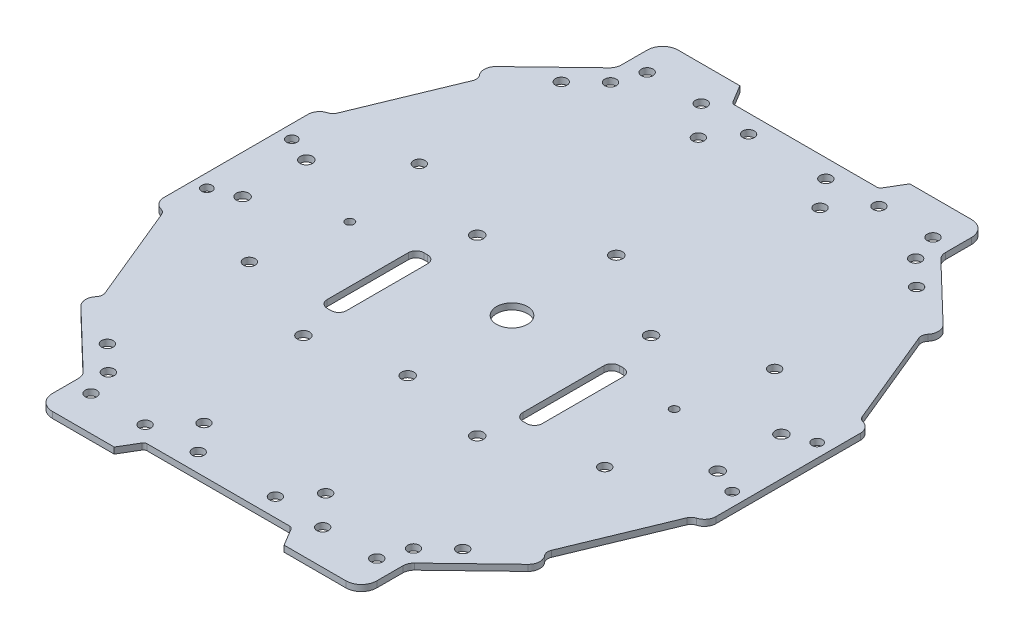
from build123d import *

# Parameters (mm, degrees)
SKETCH1_R        = 4
SKETCH1_R_2      = 1.5
SKETCH1_R_3      = 1.600010398
SKETCH1_R_4      = 1.35
SKETCH1_R_5      = 1.6
EXTRUSION1_DEPTH = 1.6
FILLET1_R        = 1
FILLET2_R        = 4
FILLET3_R        = 3
FILLET4_R        = 3
FILLET5_R        = 2
FILLET6_R        = 2
FILLET7_R        = 3
FILLET8_R        = 3
FILLET9_R        = 2
FILLET10_R       = 2
FILLET11_R       = 3


with BuildPart() as part:
    # Sketch1 → Extrusion1 (new body)
    with BuildSketch(Plane(origin=(0, 0, 0), x_dir=(-1, 0, 0), z_dir=(0, 1, 0))):
        Polygon((97.775158519, 107.059873524), (100.775158519, 102.059873961), (120.775158519, 102.059873961), (120.775158519, 114.059873961), (138.794986286, 131.388630617), (136.022385221, 134.27180306), (147.275158457, 161.559884829), (150.275158519, 161.559884829), (150.275158519, 183.059873956), (150.275158519, 204.559863083), (147.275158457, 204.559863083), (136.022385221, 231.847944851), (138.794986286, 234.731117294), (120.775158519, 252.05987395), (120.775158519, 264.05987395), (100.775158519, 264.05987395), (97.775158519, 259.059874387), (78.775158519, 259.059874387), (59.775158519, 259.059874387), (56.775158519, 264.05987395), (36.775158519, 264.05987395), (36.775158519, 252.05987395), (18.755330752, 234.731117294), (21.527931817, 231.847944851), (10.275158581, 204.559863083), (7.275158519, 204.559863083), (7.275158519, 183.059873956), (7.275158519, 161.559884829), (10.275158581, 161.559884829), (21.527931817, 134.27180306), (18.755330752, 131.388630617), (36.775158519, 114.059873961), (36.775158519, 102.059873961), (56.775158519, 102.059873961), (59.775158519, 107.059873524), (78.775158519, 107.059873524), align=None)
        with Locations((78.775158519, 183.059873956)):
            Circle(SKETCH1_R, mode=Mode.SUBTRACT)
        with Locations((41.775158457, 111.059884829)):
            Circle(SKETCH1_R_2, mode=Mode.SUBTRACT)
        with Locations((68.775158457, 111.809884829)):
            Circle(SKETCH1_R_2, mode=Mode.SUBTRACT)
        with Locations((101.275158519, 169.559873956)):
            Circle(SKETCH1_R_3, mode=Mode.SUBTRACT)
        with Locations((56.275158519, 169.559873956)):
            Circle(SKETCH1_R_3, mode=Mode.SUBTRACT)
        with Locations((10.775158457, 172.059872631)):
            Circle(SKETCH1_R_4, mode=Mode.SUBTRACT)
        with Locations((68.775158457, 254.309863083)):
            Circle(SKETCH1_R_2, mode=Mode.SUBTRACT)
        with Locations((55.775158457, 255.05987528)):
            Circle(SKETCH1_R_2, mode=Mode.SUBTRACT)
        with Locations((32.775158457, 205.059871914)):
            Circle(SKETCH1_R_2, mode=Mode.SUBTRACT)
        with Locations((17.275158457, 191.30987528)):
            Circle(SKETCH1_R_5, mode=Mode.SUBTRACT)
        with Locations((94.525158581, 119.059884829)):
            Circle(SKETCH1_R_2, mode=Mode.SUBTRACT)
        with Locations((101.775158581, 111.059872631)):
            Circle(SKETCH1_R_2, mode=Mode.SUBTRACT)
        with Locations((124.775158581, 161.059875997)):
            Circle(SKETCH1_R_2, mode=Mode.SUBTRACT)
        with Locations((146.775158581, 172.059872631)):
            Circle(SKETCH1_R_4, mode=Mode.SUBTRACT)
        with Locations((118.275158581, 248.059863083)):
            Circle(SKETCH1_R_2, mode=Mode.SUBTRACT)
        with Locations((101.775158581, 255.05987528)):
            Circle(SKETCH1_R_2, mode=Mode.SUBTRACT)
        with Locations((94.525158581, 247.059863083)):
            Circle(SKETCH1_R_2, mode=Mode.SUBTRACT)
        with Locations((124.775158581, 205.059871914)):
            Circle(SKETCH1_R_2, mode=Mode.SUBTRACT)
        with Locations((146.775158581, 194.05987528)):
            Circle(SKETCH1_R_4, mode=Mode.SUBTRACT)
        with Locations((140.275158581, 191.30987528)):
            Circle(SKETCH1_R_5, mode=Mode.SUBTRACT)
        with Locations((88.775158581, 254.309863083)):
            Circle(SKETCH1_R_2, mode=Mode.SUBTRACT)
        with Locations((115.775158581, 255.059863083)):
            Circle(SKETCH1_R_2, mode=Mode.SUBTRACT)
        with Locations((140.275158581, 174.809872631)):
            Circle(SKETCH1_R_5, mode=Mode.SUBTRACT)
        with Locations((118.275158581, 118.059884829)):
            Circle(SKETCH1_R_2, mode=Mode.SUBTRACT)
        with Locations((115.775158581, 111.059884829)):
            Circle(SKETCH1_R_2, mode=Mode.SUBTRACT)
        with Locations((88.775158581, 111.809884829)):
            Circle(SKETCH1_R_2, mode=Mode.SUBTRACT)
        with Locations((10.775158457, 194.05987528)):
            Circle(SKETCH1_R_4, mode=Mode.SUBTRACT)
        with Locations((39.275158457, 248.059863083)):
            Circle(SKETCH1_R_2, mode=Mode.SUBTRACT)
        with Locations((41.775158457, 255.059863083)):
            Circle(SKETCH1_R_2, mode=Mode.SUBTRACT)
        with Locations((63.025158457, 247.059863083)):
            Circle(SKETCH1_R_2, mode=Mode.SUBTRACT)
        with Locations((17.275158457, 174.809872631)):
            Circle(SKETCH1_R_5, mode=Mode.SUBTRACT)
        with Locations((32.775158457, 161.059875997)):
            Circle(SKETCH1_R_2, mode=Mode.SUBTRACT)
        with Locations((63.025158457, 119.059884829)):
            Circle(SKETCH1_R_2, mode=Mode.SUBTRACT)
        with Locations((39.275158457, 118.059884829)):
            Circle(SKETCH1_R_2, mode=Mode.SUBTRACT)
        with Locations((55.775158457, 111.059872631)):
            Circle(SKETCH1_R_2, mode=Mode.SUBTRACT)
        with Locations((32.775158457, 124.309884829)):
            Circle(SKETCH1_R_2, mode=Mode.SUBTRACT)
        with Locations((56.275158519, 214.559873956)):
            Circle(SKETCH1_R_3, mode=Mode.SUBTRACT)
        with Locations((32.775158457, 241.809863083)):
            Circle(SKETCH1_R_2, mode=Mode.SUBTRACT)
        with Locations((124.775158581, 124.309884829)):
            Circle(SKETCH1_R_2, mode=Mode.SUBTRACT)
        with Locations((124.775158581, 241.809863083)):
            Circle(SKETCH1_R_2, mode=Mode.SUBTRACT)
        with Locations((101.275158519, 214.559873956)):
            Circle(SKETCH1_R_3, mode=Mode.SUBTRACT)
        with BuildLine():
            Line((53.612340231, 205.400752026), (52.612340231, 205.400752026))
            ThreePointArc((52.612340231, 205.400752026), (51.198126669, 204.814965588), (50.612340231, 203.400752026))
            Line((50.612340231, 203.400752026), (50.612340231, 182.400752026))
            ThreePointArc((50.612340231, 182.400752026), (51.198126669, 180.986538463), (52.612340231, 180.400752026))
            Line((52.612340231, 180.400752026), (53.612340231, 180.400752026))
            ThreePointArc((53.612340231, 180.400752026), (55.026553793, 180.986538463), (55.612340231, 182.400752026))
            Line((55.612340231, 182.400752026), (55.612340231, 203.400752026))
            ThreePointArc((55.612340231, 203.400752026), (55.026553793, 204.814965588), (53.612340231, 205.400752026))
        make_face(mode=Mode.SUBTRACT)
        with BuildLine():
            Line((103.275158519, 205.400752026), (104.275158519, 205.400752026))
            ThreePointArc((104.275158519, 205.400752026), (105.689372082, 204.814965588), (106.275158519, 203.400752026))
            Line((106.275158519, 203.400752026), (106.275158519, 182.400752026))
            ThreePointArc((106.275158519, 182.400752026), (105.689372082, 180.986538463), (104.275158519, 180.400752026))
            Line((104.275158519, 180.400752026), (103.275158519, 180.400752026))
            ThreePointArc((103.275158519, 180.400752026), (101.860944957, 180.986538463), (101.275158519, 182.400752026))
            Line((101.275158519, 182.400752026), (101.275158519, 203.400752026))
            ThreePointArc((101.275158519, 203.400752026), (101.860944957, 204.814965588), (103.275158519, 205.400752026))
        make_face(mode=Mode.SUBTRACT)
        with BuildLine():
            ThreePointArc((78.775158457, 154.459857354), (80.375168979, 156.059867752), (78.775158457, 157.65987815))
            ThreePointArc((78.775158457, 157.65987815), (77.175148183, 156.059867752), (78.775158457, 154.459857354))
        make_face(mode=Mode.SUBTRACT)
        with BuildLine():
            ThreePointArc((35.679175461, 183.059873956), (36.775158519, 181.963890897), (37.871141578, 183.059873956))
            ThreePointArc((37.871141578, 183.059873956), (36.775158519, 184.155857014), (35.679175461, 183.059873956))
        make_face(mode=Mode.SUBTRACT)
        with BuildLine():
            ThreePointArc((78.775158457, 208.459869762), (80.375168979, 210.05988016), (78.775158457, 211.659890558))
            ThreePointArc((78.775158457, 211.659890558), (77.175148183, 210.05988016), (78.775158457, 208.459869762))
        make_face(mode=Mode.SUBTRACT)
        with BuildLine():
            ThreePointArc((121.871141578, 183.059873956), (120.775158519, 184.155857014), (119.679175461, 183.059873956))
            ThreePointArc((119.679175461, 183.059873956), (120.775158519, 181.963890897), (121.871141578, 183.059873956))
        make_face(mode=Mode.SUBTRACT)
    extrude(amount=EXTRUSION1_DEPTH)

    # Fillet1
    fillet1_edges = [part.edges().sort_by_distance(p)[0] for p in [
        (-97.775158519, 0.8, 107.059873524),
        (-59.775158519, 0.8, 107.059873524),
        (-59.775158519, 0.8, 259.059874387),
        (-97.775158519, 0.8, 259.059874387),
    ]]
    fillet(fillet1_edges, radius=FILLET1_R)

    # Fillet2
    fillet2_edges = [part.edges().sort_by_distance(p)[0] for p in [
        (-120.775158519, 0.8, 102.059873961),
        (-36.775158519, 0.8, 102.059873961),
        (-36.775158519, 0.8, 264.05987395),
        (-120.775158519, 0.8, 264.05987395),
    ]]
    fillet(fillet2_edges, radius=FILLET2_R)

    # Fillet3
    fillet3_edges = [part.edges().sort_by_distance(p)[0] for p in [
        (-120.775158519, 0.8, 114.059873961),
        (-36.775158519, 0.8, 114.059873961),
        (-36.775158519, 0.8, 252.05987395),
        (-120.775158519, 0.8, 252.05987395),
    ]]
    fillet(fillet3_edges, radius=FILLET3_R)

    # Fillet4
    fillet4_edges = [part.edges().sort_by_distance(p)[0] for p in [
        (-138.794986286, 0.8, 234.731117294),
    ]]
    fillet(fillet4_edges, radius=FILLET4_R)

    # Fillet5
    fillet5_edges = [part.edges().sort_by_distance(p)[0] for p in [
        (-136.022385221, 0.8, 231.847944851),
    ]]
    fillet(fillet5_edges, radius=FILLET5_R)

    # Fillet6
    fillet6_edges = [part.edges().sort_by_distance(p)[0] for p in [
        (-21.527931817, 0.8, 231.847944851),
    ]]
    fillet(fillet6_edges, radius=FILLET6_R)

    # Fillet7
    fillet7_edges = [part.edges().sort_by_distance(p)[0] for p in [
        (-18.755330752, 0.8, 234.731117294),
    ]]
    fillet(fillet7_edges, radius=FILLET7_R)

    # Fillet8
    fillet8_edges = [part.edges().sort_by_distance(p)[0] for p in [
        (-18.755330752, 0.8, 131.388630617),
        (-138.794986286, 0.8, 131.388630617),
    ]]
    fillet(fillet8_edges, radius=FILLET8_R)

    # Fillet9
    fillet9_edges = [part.edges().sort_by_distance(p)[0] for p in [
        (-21.527931817, 0.8, 134.27180306),
        (-136.022385221, 0.8, 134.27180306),
    ]]
    fillet(fillet9_edges, radius=FILLET9_R)

    # Fillet10
    fillet10_edges = [part.edges().sort_by_distance(p)[0] for p in [
        (-10.275158581, 0.8, 161.559884829),
        (-10.275158581, 0.8, 204.559863083),
        (-147.275158457, 0.8, 204.559863083),
        (-147.275158457, 0.8, 161.559884829),
    ]]
    fillet(fillet10_edges, radius=FILLET10_R)

    # Fillet11
    fillet11_edges = [part.edges().sort_by_distance(p)[0] for p in [
        (-150.275158519, 0.8, 161.559884829),
        (-150.275158519, 0.8, 204.559863083),
        (-7.275158519, 0.8, 204.559863083),
        (-7.275158519, 0.8, 161.559884829),
    ]]
    fillet(fillet11_edges, radius=FILLET11_R)


solid = part.part
